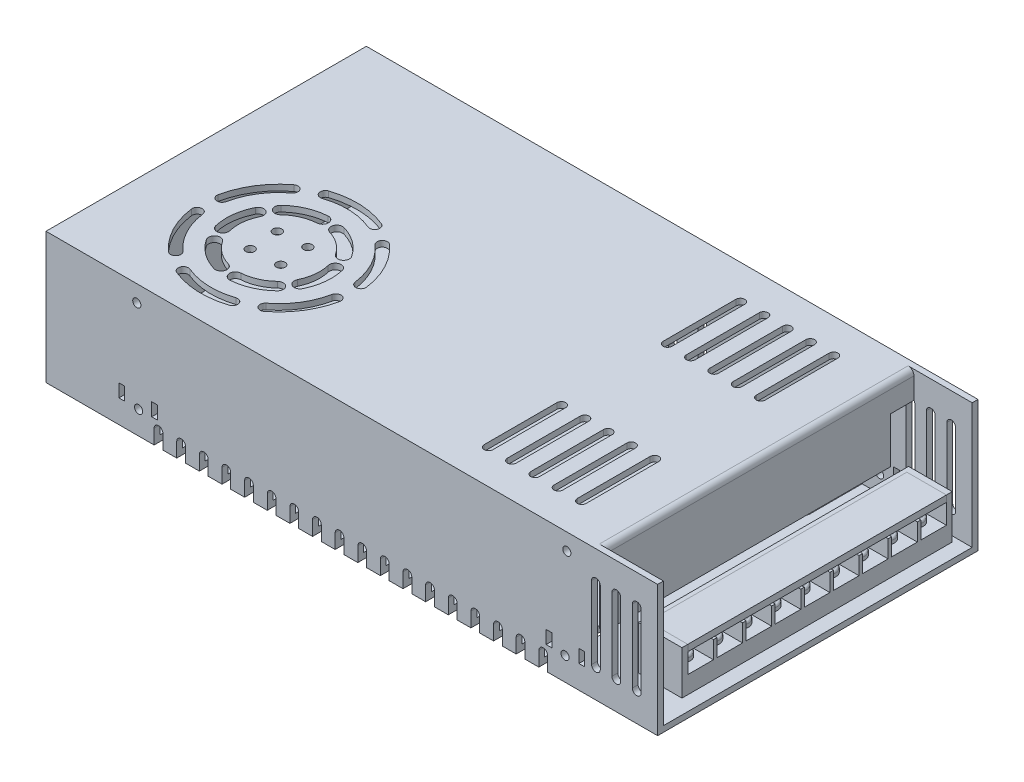
from build123d import *

# Parameters (mm, degrees)
SKETCH1_W               = 210
SKETCH1_H               = 110
BOSS_EXTRUDE1_DEPTH     = 45
SHELL1_T                = -2
SKETCH2_W               = 20
SKETCH2_H               = 106
CUT_EXTRUDE1_DEPTH      = 5
SKETCH3_W               = 2
SKETCH3_H               = 106.059252885
BOSS_EXTRUDE2_DEPTH     = 25
FILLET1_R               = 2
CUT_EXTRUDE2_DEPTH      = 10
LPATTERN1_COUNT         = 5
LPATTERN1_PITCH         = 8
MIRROR1_COPY_1_DEPTH    = 10
MIRROR1_COPY_2_DEPTH    = 10
MIRROR1_COPY_3_DEPTH    = 10
MIRROR1_COPY_4_DEPTH    = 10
CUT_EXTRUDE3_DEPTH      = 10
SKETCH7_R               = 1
BOSS_EXTRUDE3_DEPTH     = 10
CIRPATTERN1_COUNT       = 6
CUT_EXTRUDE4_DEPTH      = 10
CIRPATTERN2_COUNT       = 6
SKETCH9_R               = 1.5
CUT_EXTRUDE5_DEPTH      = 10
CIRPATTERN3_COUNT       = 4
SKETCH11_R              = 10.55358765
CUT_EXTRUDE7_DEPTH      = 34
CUT_EXTRUDE8_DEPTH      = 10
LPATTERN2_COUNT         = 3
LPATTERN2_PITCH         = 7
BOSS_EXTRUDE4_DEPTH     = 8
SKETCH15_R              = 1.4
SKETCH15_W              = 2
SKETCH15_H              = 4.5
CUT_EXTRUDE9_DEPTH      = 12
MIRROR3_COPY_1_SKETCH_R = 1.4
MIRROR3_COPY_1_SKETCH_W = 2
MIRROR3_COPY_1_SKETCH_H = 4.5
MIRROR3_COPY_1_DEPTH    = 12
MIRROR3_COPY_2_DEPTH    = 10
MIRROR3_COPY_3_DEPTH    = 10
SKETCH16_W              = 18
SKETCH16_H              = 9
CUT_EXTRUDE10_DEPTH     = 12
CUT_EXTRUDE11_DEPTH     = 5
LPATTERN3_COUNT         = 18
LPATTERN3_PITCH         = 7.77
MIRROR4_COPY_1_DEPTH    = 5
MIRROR4_COPY_2_DEPTH    = 5
MIRROR4_COPY_3_DEPTH    = 5
MIRROR4_COPY_4_DEPTH    = 5
MIRROR4_COPY_5_DEPTH    = 5
MIRROR4_COPY_6_DEPTH    = 5
MIRROR4_COPY_7_DEPTH    = 5
MIRROR4_COPY_8_DEPTH    = 5
MIRROR4_COPY_9_DEPTH    = 5
MIRROR4_COPY_10_DEPTH   = 5
MIRROR4_COPY_11_DEPTH   = 5
MIRROR4_COPY_12_DEPTH   = 5
MIRROR4_COPY_13_DEPTH   = 5
MIRROR4_COPY_14_DEPTH   = 5
MIRROR4_COPY_15_DEPTH   = 5
MIRROR4_COPY_16_DEPTH   = 5
MIRROR4_COPY_17_DEPTH   = 5
SKETCH18_R              = 1.5
CUT_EXTRUDE12_DEPTH     = 110
LPATTERN4_COUNT         = 18
LPATTERN4_PITCH         = 7.77
BOSS_EXTRUDE5_DEPTH     = 15
LPATTERN5_COUNT         = 9
LPATTERN5_PITCH         = 10
BOSS_EXTRUDE6_DEPTH     = 15
SKETCH22_W              = 88.8
SKETCH22_H              = 2.2
BOSS_EXTRUDE7_DEPTH     = 13.579516
SKETCH23_R              = 3
BOSS_EXTRUDE8_DEPTH     = 2
FILLET2_R               = 0.8
LPATTERN6_COUNT         = 9
LPATTERN6_PITCH         = 10
FILLET2_OF_LPATTERN6_R  = 0.8


with BuildPart() as part:
    # Sketch1 → Boss-Extrude1 (new body)
    with BuildSketch(Plane(origin=(0, 0, 0), x_dir=(1, 0, 0), z_dir=(0, 1, 0))):
        Rectangle(SKETCH1_W, SKETCH1_H)
    extrude(amount=BOSS_EXTRUDE1_DEPTH)

    # Shell1
    shell1_openings = [part.faces().sort_by_distance(p)[0] for p in [
        (105, 22.5, 0),
    ]]
    offset(amount=SHELL1_T, openings=shell1_openings, kind=Kind.INTERSECTION)

    # Sketch2 → Cut-Extrude1 (cut)
    with BuildSketch(Plane(origin=(0, 45, 0), x_dir=(1, 0, 0), z_dir=(0, 1, 0))):
        with Locations((95, 0)):
            Rectangle(SKETCH2_W, SKETCH2_H)
    extrude(amount=-CUT_EXTRUDE1_DEPTH, mode=Mode.SUBTRACT)

    # Sketch3 → Boss-Extrude2 (add)
    with BuildSketch(Plane(origin=(0, 45, 0), x_dir=(1, 0, 0), z_dir=(0, 1, 0))):
        with Locations((84, -0.029626443)):
            Rectangle(SKETCH3_W, SKETCH3_H)
    extrude(amount=-BOSS_EXTRUDE2_DEPTH)

    # Fillet1
    fillet1_edges = [part.edges().sort_by_distance(p)[0] for p in [
        (85, 45, 0),
    ]]
    fillet(fillet1_edges, radius=FILLET1_R)

    # Sketch5 → Cut-Extrude2 (cut)
    with BuildSketch(Plane(origin=(0, 45, 0), x_dir=(1, 0, 0), z_dir=(0, 1, 0))):
        with BuildLine():
            Line((68.667225908, 43.234598267), (68.667225908, 18.234598267))
            ThreePointArc((68.667225908, 18.234598267), (67.167225908, 16.734598267), (65.667225908, 18.234598267))
            Line((65.667225908, 18.234598267), (65.667225908, 43.234598267))
            ThreePointArc((65.667225908, 43.234598267), (67.167225908, 44.734598267), (68.667225908, 43.234598267))
        make_face()
    cut_extrude2 = extrude(amount=-CUT_EXTRUDE2_DEPTH, mode=Mode.SUBTRACT)

    # LPattern1: Cut-Extrude2 ×5
    with Locations(*[(-i * LPATTERN1_PITCH, 0, 0) for i in range(1, LPATTERN1_COUNT)]):
        add(cut_extrude2, mode=Mode.SUBTRACT)

    # Mirror1: Cut-Extrude2 across plane
    add(cut_extrude2.mirror(Plane.XY), mode=Mode.SUBTRACT)

    # Mirror1 copy 1 sketch → Mirror1 copy 1 (cut)
    with BuildSketch(Plane(origin=(-8, 45, 0), x_dir=(1, 0, 0), z_dir=(0, 1, 0))):
        with BuildLine():
            Line((68.667225908, -43.234598267), (68.667225908, -18.234598267))
            ThreePointArc((68.667225908, -18.234598267), (67.167225908, -16.734598267), (65.667225908, -18.234598267))
            Line((65.667225908, -18.234598267), (65.667225908, -43.234598267))
            ThreePointArc((65.667225908, -43.234598267), (67.167225908, -44.734598267), (68.667225908, -43.234598267))
        make_face()
    extrude(amount=-MIRROR1_COPY_1_DEPTH, mode=Mode.SUBTRACT)

    # Mirror1 copy 2 sketch → Mirror1 copy 2 (cut)
    with BuildSketch(Plane(origin=(-16, 45, 0), x_dir=(1, 0, 0), z_dir=(0, 1, 0))):
        with BuildLine():
            Line((68.667225908, -43.234598267), (68.667225908, -18.234598267))
            ThreePointArc((68.667225908, -18.234598267), (67.167225908, -16.734598267), (65.667225908, -18.234598267))
            Line((65.667225908, -18.234598267), (65.667225908, -43.234598267))
            ThreePointArc((65.667225908, -43.234598267), (67.167225908, -44.734598267), (68.667225908, -43.234598267))
        make_face()
    extrude(amount=-MIRROR1_COPY_2_DEPTH, mode=Mode.SUBTRACT)

    # Mirror1 copy 3 sketch → Mirror1 copy 3 (cut)
    with BuildSketch(Plane(origin=(-24, 45, 0), x_dir=(1, 0, 0), z_dir=(0, 1, 0))):
        with BuildLine():
            Line((68.667225908, -43.234598267), (68.667225908, -18.234598267))
            ThreePointArc((68.667225908, -18.234598267), (67.167225908, -16.734598267), (65.667225908, -18.234598267))
            Line((65.667225908, -18.234598267), (65.667225908, -43.234598267))
            ThreePointArc((65.667225908, -43.234598267), (67.167225908, -44.734598267), (68.667225908, -43.234598267))
        make_face()
    extrude(amount=-MIRROR1_COPY_3_DEPTH, mode=Mode.SUBTRACT)

    # Mirror1 copy 4 sketch → Mirror1 copy 4 (cut)
    with BuildSketch(Plane(origin=(-32, 45, 0), x_dir=(1, 0, 0), z_dir=(0, 1, 0))):
        with BuildLine():
            Line((68.667225908, -43.234598267), (68.667225908, -18.234598267))
            ThreePointArc((68.667225908, -18.234598267), (67.167225908, -16.734598267), (65.667225908, -18.234598267))
            Line((65.667225908, -18.234598267), (65.667225908, -43.234598267))
            ThreePointArc((65.667225908, -43.234598267), (67.167225908, -44.734598267), (68.667225908, -43.234598267))
        make_face()
    extrude(amount=-MIRROR1_COPY_4_DEPTH, mode=Mode.SUBTRACT)

    # Sketch6 → Cut-Extrude3 (cut)
    with BuildSketch(Plane(origin=(0, 45, 0), x_dir=(1, 0, 0), z_dir=(0, 1, 0))):
        with BuildLine():
            ThreePointArc((-76.126580706, -12.004163912), (-77.888765892, -18.001987276), (-77.493301902, -24.240800461))
            ThreePointArc((-77.493301902, -24.240800461), (-75.07840164, -25.713300621), (-73.60590148, -23.298400359))
            ThreePointArc((-73.60590148, -23.298400359), (-73.913484583, -18.445990103), (-72.542896104, -13.781016376))
            ThreePointArc((-72.542896104, -13.781016376), (-73.446312173, -11.100747844), (-76.126580706, -12.004163912))
        make_face()
    cut_extrude3 = extrude(amount=-CUT_EXTRUDE3_DEPTH, mode=Mode.SUBTRACT)

    # Sketch7 → Boss-Extrude3 (add)
    with BuildSketch(Plane(origin=(0, 45, 0), x_dir=(1, 0, 0), z_dir=(0, 1, 0))):
        with Locations((-60, -20)):
            Circle(SKETCH7_R)
    extrude(amount=BOSS_EXTRUDE3_DEPTH)

    # CirPattern1: Cut-Extrude3 ×6 about axis
    cirpattern1_axis = Axis((-60, 0, 20), (0, 1, 0))
    for i in range(1, CIRPATTERN1_COUNT):
        add(cut_extrude3.rotate(cirpattern1_axis, i * 360 / CIRPATTERN1_COUNT), mode=Mode.SUBTRACT)

    # Sketch8 → Cut-Extrude4 (cut)
    with BuildSketch(Plane(origin=(0, 45, 0), x_dir=(1, 0, 0), z_dir=(0, 1, 0))):
        with BuildLine():
            ThreePointArc((-49.631163755, 4.789663915), (-58.982111091, 6.851519589), (-68.462319546, 5.503516424))
            ThreePointArc((-68.462319546, 5.503516424), (-69.572152084, 3.291442343), (-67.360078003, 2.181609806))
            ThreePointArc((-67.360078003, 2.181609806), (-59.114694059, 3.354031668), (-50.981734601, 1.560738646))
            ThreePointArc((-50.981734601, 1.560738646), (-48.691986543, 2.499915858), (-49.631163755, 4.789663915))
        make_face()
    cut_extrude4 = extrude(amount=-CUT_EXTRUDE4_DEPTH, mode=Mode.SUBTRACT)

    # CirPattern2: Cut-Extrude4 ×6 about axis
    cirpattern2_axis = Axis((-60, 0, 20), (0, 1, 0))
    for i in range(1, CIRPATTERN2_COUNT):
        add(cut_extrude4.rotate(cirpattern2_axis, i * 360 / CIRPATTERN2_COUNT), mode=Mode.SUBTRACT)

    # Sketch9 → Cut-Extrude5 (cut)
    with BuildSketch(Plane(origin=(0, 45, 0), x_dir=(1, 0, 0), z_dir=(0, 1, 0))):
        with Locations((-65.251746577, -15.339111647)):
            Circle(SKETCH9_R)
    cut_extrude5 = extrude(amount=-CUT_EXTRUDE5_DEPTH, mode=Mode.SUBTRACT)

    # CirPattern3: Cut-Extrude5 ×4 about axis
    cirpattern3_axis = Axis((-60, 0, 20), (0, 1, 0))
    for i in range(1, CIRPATTERN3_COUNT):
        add(cut_extrude5.rotate(cirpattern3_axis, i * 360 / CIRPATTERN3_COUNT), mode=Mode.SUBTRACT)

    # Sketch11 → Cut-Extrude7 (cut)
    with BuildSketch(Plane(origin=(0, 45, 0), x_dir=(1, 0, 0), z_dir=(0, 1, 0))):
        with Locations((-60.781994225, -15.339111647)):
            Circle(SKETCH11_R)
    extrude(amount=CUT_EXTRUDE7_DEPTH, mode=Mode.SUBTRACT)

    # Sketch12 → Cut-Extrude8 (cut)
    with BuildSketch(Plane.XY.offset(55)):
        with BuildLine():
            Line((99.310306938, 34.811336335), (99.310306938, 9.811336335))
            ThreePointArc((99.310306938, 9.811336335), (97.810306938, 8.311336335), (96.310306938, 9.811336335))
            Line((96.310306938, 9.811336335), (96.310306938, 34.811336335))
            ThreePointArc((96.310306938, 34.811336335), (97.810306938, 36.311336335), (99.310306938, 34.811336335))
        make_face()
    cut_extrude8 = extrude(amount=-CUT_EXTRUDE8_DEPTH, mode=Mode.SUBTRACT)

    # LPattern2: Cut-Extrude8 ×3
    with Locations(*[(-i * LPATTERN2_PITCH, 0, 0) for i in range(1, LPATTERN2_COUNT)]):
        add(cut_extrude8, mode=Mode.SUBTRACT)

    # Sketch14 → Boss-Extrude4 (add)
    with BuildSketch(Plane.XY.offset(45)):
        with BuildLine():
            Line((85, 20), (85, 35.724917431))
            ThreePointArc((85, 35.724917431), (84.067959362, 36.289042405), (83, 36.07363688))
            Line((83, 36.07363688), (83, 20))
            Line((83, 20), (85, 20))
        make_face()
    extrude(amount=BOSS_EXTRUDE4_DEPTH)

    # Sketch15 → Cut-Extrude9 (cut)
    with BuildSketch(Plane.XY.offset(55)):
        with Locations((73.21011849, 7.964461941)):
            Circle(SKETCH15_R)
        with Locations((73.828092009, 39.283545421)):
            Circle(SKETCH15_R)
        with Locations((78.969458419, 10.214461941)):
            Rectangle(SKETCH15_W, SKETCH15_H)
        with Locations((67.71011849, 10.214461941)):
            Rectangle(SKETCH15_W, SKETCH15_H)
    cut_extrude9 = extrude(amount=-CUT_EXTRUDE9_DEPTH, mode=Mode.SUBTRACT)

    # Mirror2: Cut-Extrude9 across plane
    add(cut_extrude9.mirror(Plane(origin=(0, 0, 0), x_dir=(0, 0, 1), z_dir=(1, 0, 0))), mode=Mode.SUBTRACT)

    # Mirror3: Cut-Extrude9, Cut-Extrude8 across plane
    add(cut_extrude9.mirror(Plane.XY), mode=Mode.SUBTRACT)
    add(cut_extrude8.mirror(Plane.XY), mode=Mode.SUBTRACT)

    # Mirror3 copy 1 sketch → Mirror3 copy 1 (cut)
    with BuildSketch(Plane(origin=(0, 0, -55), x_dir=(-1, 0, 0), z_dir=(0, 0, -1))):
        with Locations((73.21011849, 7.964461941)):
            Circle(MIRROR3_COPY_1_SKETCH_R)
        with Locations((73.828092009, 39.283545421)):
            Circle(MIRROR3_COPY_1_SKETCH_R)
        with Locations((78.969458419, 10.214461941)):
            Rectangle(MIRROR3_COPY_1_SKETCH_W, MIRROR3_COPY_1_SKETCH_H)
        with Locations((67.71011849, 10.214461941)):
            Rectangle(MIRROR3_COPY_1_SKETCH_W, MIRROR3_COPY_1_SKETCH_H)
    extrude(amount=-MIRROR3_COPY_1_DEPTH, mode=Mode.SUBTRACT)

    # Mirror3 copy 2 sketch → Mirror3 copy 2 (cut)
    with BuildSketch(Plane(origin=(-7, 0, -55), x_dir=(1, 0, 0), z_dir=(0, 0, -1))):
        with BuildLine():
            Line((99.310306938, -34.811336335), (99.310306938, -9.811336335))
            ThreePointArc((99.310306938, -9.811336335), (97.810306938, -8.311336335), (96.310306938, -9.811336335))
            Line((96.310306938, -9.811336335), (96.310306938, -34.811336335))
            ThreePointArc((96.310306938, -34.811336335), (97.810306938, -36.311336335), (99.310306938, -34.811336335))
        make_face()
    extrude(amount=-MIRROR3_COPY_2_DEPTH, mode=Mode.SUBTRACT)

    # Mirror3 copy 3 sketch → Mirror3 copy 3 (cut)
    with BuildSketch(Plane(origin=(-14, 0, -55), x_dir=(1, 0, 0), z_dir=(0, 0, -1))):
        with BuildLine():
            Line((99.310306938, -34.811336335), (99.310306938, -9.811336335))
            ThreePointArc((99.310306938, -9.811336335), (97.810306938, -8.311336335), (96.310306938, -9.811336335))
            Line((96.310306938, -9.811336335), (96.310306938, -34.811336335))
            ThreePointArc((96.310306938, -34.811336335), (97.810306938, -36.311336335), (99.310306938, -34.811336335))
        make_face()
    extrude(amount=-MIRROR3_COPY_3_DEPTH, mode=Mode.SUBTRACT)

    # Sketch16 → Cut-Extrude10 (cut)
    with BuildSketch(Plane(origin=(0, 0, -55), x_dir=(-1, 0, 0), z_dir=(0, 0, -1))):
        with BuildLine():
            Line((-10.842193564, 34.811336335), (-10.842193564, 9.811336335))
            ThreePointArc((-10.842193564, 9.811336335), (-12.342193564, 8.311336335), (-13.842193564, 9.811336335))
            Line((-13.842193564, 9.811336335), (-13.842193564, 34.811336335))
            ThreePointArc((-13.842193564, 34.811336335), (-12.342193564, 36.311336335), (-10.842193564, 34.811336335))
        make_face()
        with BuildLine():
            Line((-0.65710264, 34.811336335), (-0.65710264, 9.811336335))
            ThreePointArc((-0.65710264, 9.811336335), (-2.15710264, 8.311336335), (-3.65710264, 9.811336335))
            Line((-3.65710264, 9.811336335), (-3.65710264, 34.811336335))
            ThreePointArc((-3.65710264, 34.811336335), (-2.15710264, 36.311336335), (-0.65710264, 34.811336335))
        make_face()
        with Locations((19.842193564, 12.050914934)):
            Rectangle(SKETCH16_W, SKETCH16_H)
    extrude(amount=-CUT_EXTRUDE10_DEPTH, mode=Mode.SUBTRACT)

    # Sketch17 → Cut-Extrude11 (cut)
    with BuildSketch(Plane.XZ):
        with BuildLine():
            Line((64.210264027, -55), (64.210264027, -35))
            ThreePointArc((64.210264027, -35), (65.710264027, -33.5), (67.210264027, -35))
            Line((67.210264027, -35), (67.210264027, -55))
            ThreePointArc((67.210264027, -55), (65.710264027, -56.5), (64.210264027, -55))
        make_face()
    cut_extrude11 = extrude(amount=-CUT_EXTRUDE11_DEPTH, mode=Mode.SUBTRACT)

    # LPattern3: Cut-Extrude11 ×18
    with Locations(*[(-i * LPATTERN3_PITCH, 0, 0) for i in range(1, LPATTERN3_COUNT)]):
        add(cut_extrude11, mode=Mode.SUBTRACT)

    # Mirror4: Cut-Extrude11 across plane
    add(cut_extrude11.mirror(Plane.XY), mode=Mode.SUBTRACT)

    # Mirror4 copy 1 sketch → Mirror4 copy 1 (cut)
    with BuildSketch(Plane(origin=(-7.77, 0, 0), x_dir=(1, 0, 0), z_dir=(0, -1, 0))):
        with BuildLine():
            Line((64.210264027, 55), (64.210264027, 35))
            ThreePointArc((64.210264027, 35), (65.710264027, 33.5), (67.210264027, 35))
            Line((67.210264027, 35), (67.210264027, 55))
            ThreePointArc((67.210264027, 55), (65.710264027, 56.5), (64.210264027, 55))
        make_face()
    extrude(amount=-MIRROR4_COPY_1_DEPTH, mode=Mode.SUBTRACT)

    # Mirror4 copy 2 sketch → Mirror4 copy 2 (cut)
    with BuildSketch(Plane(origin=(-15.54, 0, 0), x_dir=(1, 0, 0), z_dir=(0, -1, 0))):
        with BuildLine():
            Line((64.210264027, 55), (64.210264027, 35))
            ThreePointArc((64.210264027, 35), (65.710264027, 33.5), (67.210264027, 35))
            Line((67.210264027, 35), (67.210264027, 55))
            ThreePointArc((67.210264027, 55), (65.710264027, 56.5), (64.210264027, 55))
        make_face()
    extrude(amount=-MIRROR4_COPY_2_DEPTH, mode=Mode.SUBTRACT)

    # Mirror4 copy 3 sketch → Mirror4 copy 3 (cut)
    with BuildSketch(Plane(origin=(-23.31, 0, 0), x_dir=(1, 0, 0), z_dir=(0, -1, 0))):
        with BuildLine():
            Line((64.210264027, 55), (64.210264027, 35))
            ThreePointArc((64.210264027, 35), (65.710264027, 33.5), (67.210264027, 35))
            Line((67.210264027, 35), (67.210264027, 55))
            ThreePointArc((67.210264027, 55), (65.710264027, 56.5), (64.210264027, 55))
        make_face()
    extrude(amount=-MIRROR4_COPY_3_DEPTH, mode=Mode.SUBTRACT)

    # Mirror4 copy 4 sketch → Mirror4 copy 4 (cut)
    with BuildSketch(Plane(origin=(-31.08, 0, 0), x_dir=(1, 0, 0), z_dir=(0, -1, 0))):
        with BuildLine():
            Line((64.210264027, 55), (64.210264027, 35))
            ThreePointArc((64.210264027, 35), (65.710264027, 33.5), (67.210264027, 35))
            Line((67.210264027, 35), (67.210264027, 55))
            ThreePointArc((67.210264027, 55), (65.710264027, 56.5), (64.210264027, 55))
        make_face()
    extrude(amount=-MIRROR4_COPY_4_DEPTH, mode=Mode.SUBTRACT)

    # Mirror4 copy 5 sketch → Mirror4 copy 5 (cut)
    with BuildSketch(Plane(origin=(-38.85, 0, 0), x_dir=(1, 0, 0), z_dir=(0, -1, 0))):
        with BuildLine():
            Line((64.210264027, 55), (64.210264027, 35))
            ThreePointArc((64.210264027, 35), (65.710264027, 33.5), (67.210264027, 35))
            Line((67.210264027, 35), (67.210264027, 55))
            ThreePointArc((67.210264027, 55), (65.710264027, 56.5), (64.210264027, 55))
        make_face()
    extrude(amount=-MIRROR4_COPY_5_DEPTH, mode=Mode.SUBTRACT)

    # Mirror4 copy 6 sketch → Mirror4 copy 6 (cut)
    with BuildSketch(Plane(origin=(-46.62, 0, 0), x_dir=(1, 0, 0), z_dir=(0, -1, 0))):
        with BuildLine():
            Line((64.210264027, 55), (64.210264027, 35))
            ThreePointArc((64.210264027, 35), (65.710264027, 33.5), (67.210264027, 35))
            Line((67.210264027, 35), (67.210264027, 55))
            ThreePointArc((67.210264027, 55), (65.710264027, 56.5), (64.210264027, 55))
        make_face()
    extrude(amount=-MIRROR4_COPY_6_DEPTH, mode=Mode.SUBTRACT)

    # Mirror4 copy 7 sketch → Mirror4 copy 7 (cut)
    with BuildSketch(Plane(origin=(-54.39, 0, 0), x_dir=(1, 0, 0), z_dir=(0, -1, 0))):
        with BuildLine():
            Line((64.210264027, 55), (64.210264027, 35))
            ThreePointArc((64.210264027, 35), (65.710264027, 33.5), (67.210264027, 35))
            Line((67.210264027, 35), (67.210264027, 55))
            ThreePointArc((67.210264027, 55), (65.710264027, 56.5), (64.210264027, 55))
        make_face()
    extrude(amount=-MIRROR4_COPY_7_DEPTH, mode=Mode.SUBTRACT)

    # Mirror4 copy 8 sketch → Mirror4 copy 8 (cut)
    with BuildSketch(Plane(origin=(-62.16, 0, 0), x_dir=(1, 0, 0), z_dir=(0, -1, 0))):
        with BuildLine():
            Line((64.210264027, 55), (64.210264027, 35))
            ThreePointArc((64.210264027, 35), (65.710264027, 33.5), (67.210264027, 35))
            Line((67.210264027, 35), (67.210264027, 55))
            ThreePointArc((67.210264027, 55), (65.710264027, 56.5), (64.210264027, 55))
        make_face()
    extrude(amount=-MIRROR4_COPY_8_DEPTH, mode=Mode.SUBTRACT)

    # Mirror4 copy 9 sketch → Mirror4 copy 9 (cut)
    with BuildSketch(Plane(origin=(-69.93, 0, 0), x_dir=(1, 0, 0), z_dir=(0, -1, 0))):
        with BuildLine():
            Line((64.210264027, 55), (64.210264027, 35))
            ThreePointArc((64.210264027, 35), (65.710264027, 33.5), (67.210264027, 35))
            Line((67.210264027, 35), (67.210264027, 55))
            ThreePointArc((67.210264027, 55), (65.710264027, 56.5), (64.210264027, 55))
        make_face()
    extrude(amount=-MIRROR4_COPY_9_DEPTH, mode=Mode.SUBTRACT)

    # Mirror4 copy 10 sketch → Mirror4 copy 10 (cut)
    with BuildSketch(Plane(origin=(-77.7, 0, 0), x_dir=(1, 0, 0), z_dir=(0, -1, 0))):
        with BuildLine():
            Line((64.210264027, 55), (64.210264027, 35))
            ThreePointArc((64.210264027, 35), (65.710264027, 33.5), (67.210264027, 35))
            Line((67.210264027, 35), (67.210264027, 55))
            ThreePointArc((67.210264027, 55), (65.710264027, 56.5), (64.210264027, 55))
        make_face()
    extrude(amount=-MIRROR4_COPY_10_DEPTH, mode=Mode.SUBTRACT)

    # Mirror4 copy 11 sketch → Mirror4 copy 11 (cut)
    with BuildSketch(Plane(origin=(-85.47, 0, 0), x_dir=(1, 0, 0), z_dir=(0, -1, 0))):
        with BuildLine():
            Line((64.210264027, 55), (64.210264027, 35))
            ThreePointArc((64.210264027, 35), (65.710264027, 33.5), (67.210264027, 35))
            Line((67.210264027, 35), (67.210264027, 55))
            ThreePointArc((67.210264027, 55), (65.710264027, 56.5), (64.210264027, 55))
        make_face()
    extrude(amount=-MIRROR4_COPY_11_DEPTH, mode=Mode.SUBTRACT)

    # Mirror4 copy 12 sketch → Mirror4 copy 12 (cut)
    with BuildSketch(Plane(origin=(-93.24, 0, 0), x_dir=(1, 0, 0), z_dir=(0, -1, 0))):
        with BuildLine():
            Line((64.210264027, 55), (64.210264027, 35))
            ThreePointArc((64.210264027, 35), (65.710264027, 33.5), (67.210264027, 35))
            Line((67.210264027, 35), (67.210264027, 55))
            ThreePointArc((67.210264027, 55), (65.710264027, 56.5), (64.210264027, 55))
        make_face()
    extrude(amount=-MIRROR4_COPY_12_DEPTH, mode=Mode.SUBTRACT)

    # Mirror4 copy 13 sketch → Mirror4 copy 13 (cut)
    with BuildSketch(Plane(origin=(-101.01, 0, 0), x_dir=(1, 0, 0), z_dir=(0, -1, 0))):
        with BuildLine():
            Line((64.210264027, 55), (64.210264027, 35))
            ThreePointArc((64.210264027, 35), (65.710264027, 33.5), (67.210264027, 35))
            Line((67.210264027, 35), (67.210264027, 55))
            ThreePointArc((67.210264027, 55), (65.710264027, 56.5), (64.210264027, 55))
        make_face()
    extrude(amount=-MIRROR4_COPY_13_DEPTH, mode=Mode.SUBTRACT)

    # Mirror4 copy 14 sketch → Mirror4 copy 14 (cut)
    with BuildSketch(Plane(origin=(-108.78, 0, 0), x_dir=(1, 0, 0), z_dir=(0, -1, 0))):
        with BuildLine():
            Line((64.210264027, 55), (64.210264027, 35))
            ThreePointArc((64.210264027, 35), (65.710264027, 33.5), (67.210264027, 35))
            Line((67.210264027, 35), (67.210264027, 55))
            ThreePointArc((67.210264027, 55), (65.710264027, 56.5), (64.210264027, 55))
        make_face()
    extrude(amount=-MIRROR4_COPY_14_DEPTH, mode=Mode.SUBTRACT)

    # Mirror4 copy 15 sketch → Mirror4 copy 15 (cut)
    with BuildSketch(Plane(origin=(-116.55, 0, 0), x_dir=(1, 0, 0), z_dir=(0, -1, 0))):
        with BuildLine():
            Line((64.210264027, 55), (64.210264027, 35))
            ThreePointArc((64.210264027, 35), (65.710264027, 33.5), (67.210264027, 35))
            Line((67.210264027, 35), (67.210264027, 55))
            ThreePointArc((67.210264027, 55), (65.710264027, 56.5), (64.210264027, 55))
        make_face()
    extrude(amount=-MIRROR4_COPY_15_DEPTH, mode=Mode.SUBTRACT)

    # Mirror4 copy 16 sketch → Mirror4 copy 16 (cut)
    with BuildSketch(Plane(origin=(-124.32, 0, 0), x_dir=(1, 0, 0), z_dir=(0, -1, 0))):
        with BuildLine():
            Line((64.210264027, 55), (64.210264027, 35))
            ThreePointArc((64.210264027, 35), (65.710264027, 33.5), (67.210264027, 35))
            Line((67.210264027, 35), (67.210264027, 55))
            ThreePointArc((67.210264027, 55), (65.710264027, 56.5), (64.210264027, 55))
        make_face()
    extrude(amount=-MIRROR4_COPY_16_DEPTH, mode=Mode.SUBTRACT)

    # Mirror4 copy 17 sketch → Mirror4 copy 17 (cut)
    with BuildSketch(Plane(origin=(-132.09, 0, 0), x_dir=(1, 0, 0), z_dir=(0, -1, 0))):
        with BuildLine():
            Line((64.210264027, 55), (64.210264027, 35))
            ThreePointArc((64.210264027, 35), (65.710264027, 33.5), (67.210264027, 35))
            Line((67.210264027, 35), (67.210264027, 55))
            ThreePointArc((67.210264027, 55), (65.710264027, 56.5), (64.210264027, 55))
        make_face()
    extrude(amount=-MIRROR4_COPY_17_DEPTH, mode=Mode.SUBTRACT)

    # Sketch18 → Cut-Extrude12 (cut)
    with BuildSketch(Plane(origin=(0, 0, -55), x_dir=(-1, 0, 0), z_dir=(0, 0, -1))):
        with Locations((-65.710264027, 5)):
            Circle(SKETCH18_R)
    cut_extrude12 = extrude(amount=-CUT_EXTRUDE12_DEPTH, mode=Mode.SUBTRACT)

    # LPattern4: Cut-Extrude12 ×18
    with Locations(*[(-i * LPATTERN4_PITCH, 0, 0) for i in range(1, LPATTERN4_COUNT)]):
        add(cut_extrude12, mode=Mode.SUBTRACT)

    # Sketch20 → Boss-Extrude5 (add)
    with BuildSketch(Plane(origin=(85, 0, 0), x_dir=(0, 0, -1), z_dir=(1, 0, 0))):
        Polygon((40.354709736, 8), (49.154709736, 8), (49.154709736, 14), (49.754709736, 14), (49.754709736, 8), (49.754709736, 2), (39.754709736, 2), (39.754709736, 8), (39.754709736, 14), (40.354709736, 14), align=None)
    boss_extrude5 = extrude(amount=BOSS_EXTRUDE5_DEPTH)

    # LPattern5: Boss-Extrude5 ×9
    with Locations(*[(0, 0, i * LPATTERN5_PITCH) for i in range(1, LPATTERN5_COUNT)]):
        add(boss_extrude5)

    # Sketch21 → Boss-Extrude6 (add)
    with BuildSketch(Plane(origin=(0, 2, 0), x_dir=(1, 0, 0), z_dir=(0, 1, 0))):
        Polygon((86.420484082, -39.645290264), (100, -39.645290264), (100, -41.645290264), (85, -41.645290264), (85, -39.645290264), (85, 49.154709736), (85, 51.154709736), (100, 51.154709736), (100, 49.154709736), (86.420484082, 49.154709736), align=None)
    extrude(amount=BOSS_EXTRUDE6_DEPTH)

    # Sketch23 → Boss-Extrude8 (add)
    with BuildSketch(Plane(origin=(0, 8, 0), x_dir=(1, 0, 0), z_dir=(0, 1, 0))):
        with Locations((93.365231943, 44.763710042)):
            Circle(SKETCH23_R)
    boss_extrude8 = extrude(amount=BOSS_EXTRUDE8_DEPTH)

    # Fillet2
    fillet2_edges = [part.edges().sort_by_distance(p)[0] for p in [
        (90.365231943, 10, -44.763710042),
    ]]
    fillet(fillet2_edges, radius=FILLET2_R)

    # LPattern6: Boss-Extrude8 ×9
    with Locations(*[(0, 0, i * LPATTERN6_PITCH) for i in range(1, LPATTERN6_COUNT)]):
        add(boss_extrude8)

    # Fillet2 of LPattern6
    fillet2_of_lpattern6_edges = [part.edges().sort_by_distance(p)[0] for p in [
        (90.365231943, 10, -34.763710042),
        (90.365231943, 10, -24.763710042),
        (90.365231943, 10, -14.763710042),
        (90.365231943, 10, -4.763710042),
        (90.365231943, 10, 5.236289958),
        (90.365231943, 10, 15.236289958),
        (90.365231943, 10, 25.236289958),
        (90.365231943, 10, 35.236289958),
    ]]
    fillet(fillet2_of_lpattern6_edges, radius=FILLET2_OF_LPATTERN6_R)


with BuildPart() as body_2:
    # Sketch22 → Boss-Extrude7 (new body)
    with BuildSketch(Plane(origin=(86.420484082, 0, 0), x_dir=(0, 0, -1), z_dir=(1, 0, 0))):
        with Locations((4.754709736, 15.9)):
            Rectangle(SKETCH22_W, SKETCH22_H)
    extrude(amount=BOSS_EXTRUDE7_DEPTH)


solid = Compound([part.part, body_2.part])
